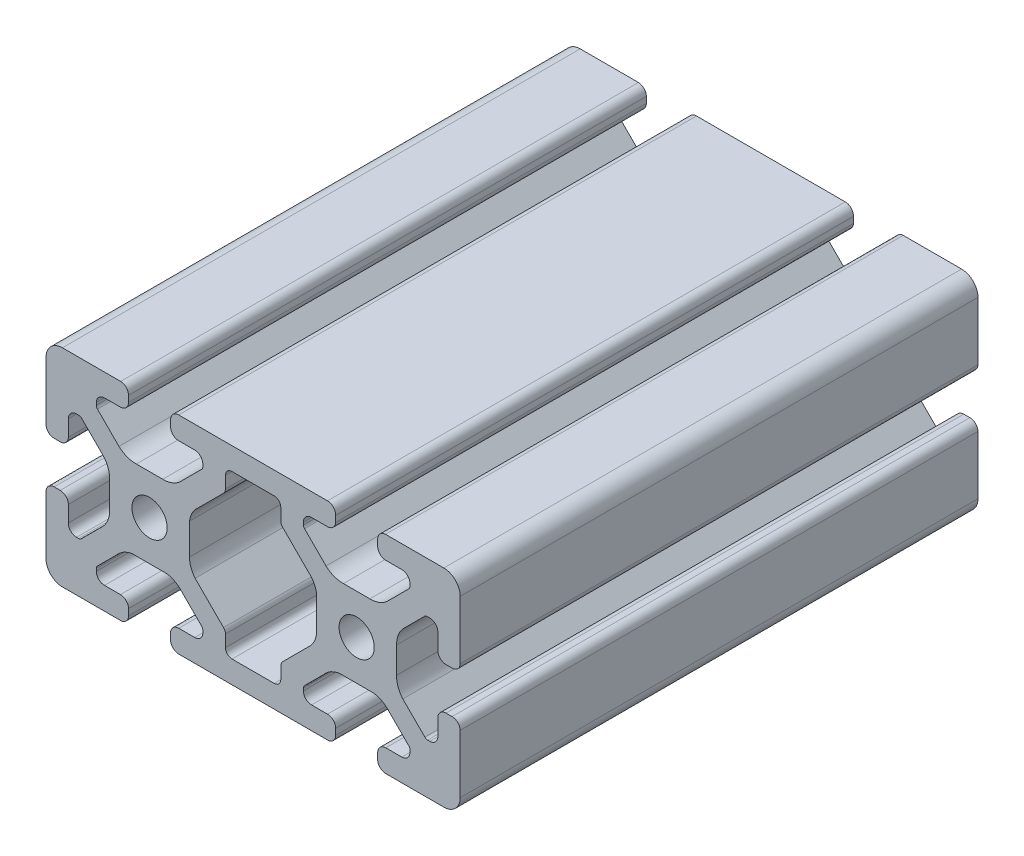
from build123d import *

# Parameters (mm, degrees)
SKETCH1_R           = 3.4
BOSS_EXTRUDE1_DEPTH = 100


with BuildPart() as part:
    # Sketch1 → Boss-Extrude1 (new body)
    with BuildSketch(Plane.XY):
        with BuildLine():
            Line((-14.371895096, 20), (14.371895096, 20))
            ThreePointArc((14.371895096, 20), (15.50899084, 19.51254943), (15.94, 18.352883145))
            Line((15.94, 18.352883145), (15.94, 17.172883145))
            ThreePointArc((15.94, 17.172883145), (15.453758432, 16.112250378), (14.37, 15.68))
            Line((14.37, 15.68), (11.285, 15.68))
            ThreePointArc((11.285, 15.68), (10.174842354, 15.220157646), (9.715, 14.11))
            Line((9.715, 14.11), (9.715, 13.654503602))
            ThreePointArc((9.715, 13.654503602), (9.772851555, 13.363664194), (9.937598846, 13.117102448))
            Line((9.937598846, 13.117102448), (14.091872782, 8.962828513))
            ThreePointArc((14.091872782, 8.962828513), (15.647416634, 8.002049766), (17.450629992, 7.7))
            Line((17.450629992, 7.7), (22.549370008, 7.7))
            ThreePointArc((22.549370008, 7.7), (24.352583366, 8.002049766), (25.908127218, 8.962828513))
            Line((25.908127218, 8.962828513), (30.062401154, 13.117102448))
            ThreePointArc((30.062401154, 13.117102448), (30.227148445, 13.363664194), (30.285, 13.654503602))
            Line((30.285, 13.654503602), (30.285, 14.11))
            ThreePointArc((30.285, 14.11), (29.825157646, 15.220157646), (28.715, 15.68))
            Line((28.715, 15.68), (25.63, 15.68))
            ThreePointArc((25.63, 15.68), (24.519842354, 16.139842354), (24.06, 17.25))
            Line((24.06, 17.25), (24.06, 18.431164164))
            ThreePointArc((24.06, 18.431164164), (24.498672143, 19.519739968), (25.569550674, 20))
            Line((25.569550674, 20), (33, 20))
            Line((33, 20), (36.83, 20))
            ThreePointArc((36.83, 20), (39.067780363, 19.075288119), (40, 16.840624931))
            Line((40, 16.840624931), (40, 13.010624931))
            Line((40, 13.010624931), (40, 5.582508737))
            ThreePointArc((40, 5.582508737), (39.486387554, 4.464397964), (38.324306777, 4.06))
            Line((38.324306777, 4.06), (37.144306789, 4.06))
            ThreePointArc((37.144306789, 4.06), (36.103082753, 4.554299861), (35.68, 5.626438298))
            Line((35.68, 5.626438298), (35.68, 8.711438298))
            ThreePointArc((35.68, 8.711438298), (35.220157646, 9.821595945), (34.11, 10.281438298))
            Line((34.11, 10.281438298), (33.650941901, 10.281438298))
            ThreePointArc((33.650941901, 10.281438298), (33.360102492, 10.223586743), (33.113540747, 10.058839452))
            Line((33.113540747, 10.058839452), (29.01112516, 5.956423865))
            ThreePointArc((29.01112516, 5.956423865), (28.027864944, 4.392105869), (27.715866667, 2.570966522))
            Line((27.715866667, 2.570966522), (27.715866667, -2.502014759))
            ThreePointArc((27.715866667, -2.502014759), (27.988460835, -4.298258683), (28.915473265, -5.86077197))
            Line((28.915473265, -5.86077197), (33.171894658, -10.117193363))
            ThreePointArc((33.171894658, -10.117193363), (33.418456403, -10.281940654), (33.709295811, -10.339792209))
            Line((33.709295811, -10.339792209), (34.110956402, -10.339792209))
            ThreePointArc((34.110956402, -10.339792209), (35.240319888, -9.860405851), (35.68, -8.714999999))
            Line((35.68, -8.714999999), (35.68, -5.629999999))
            ThreePointArc((35.68, -5.629999999), (36.139842353, -4.519842353), (37.249999999, -4.06))
            Line((37.249999999, -4.06), (38.431164149, -4.06))
            ThreePointArc((38.431164149, -4.06), (39.519739962, -4.498672137), (40, -5.569550674))
            Line((40, -5.569550674), (40, -13))
            Line((40, -13), (40, -16.83))
            ThreePointArc((40, -16.83), (39.153330856, -18.99480488), (37.057427332, -20))
            Line((37.057427332, -20), (33.227427332, -20))
            Line((33.227427332, -20), (25.796978006, -20))
            ThreePointArc((25.796978006, -20), (24.580537154, -19.606606664), (24.06, -18.438904761))
            Line((24.06, -18.438904761), (24.06, -17.25))
            ThreePointArc((24.06, -17.25), (24.519842354, -16.139842354), (25.63, -15.68))
            Line((25.63, -15.68), (28.715, -15.68))
            ThreePointArc((28.715, -15.68), (29.825157646, -15.220157646), (30.285, -14.11))
            Line((30.285, -14.11), (30.285, -13.654503602))
            ThreePointArc((30.285, -13.654503602), (30.227148445, -13.363664194), (30.062401154, -13.117102448))
            Line((30.062401154, -13.117102448), (26.309520343, -9.364221638))
            ThreePointArc((26.309520343, -9.364221638), (24.979669869, -8.257223741), (23.341546451, -7.7))
            Line((23.341546451, -7.7), (16.658453549, -7.7))
            ThreePointArc((16.658453549, -7.7), (15.020330131, -8.257223741), (13.690479657, -9.364221638))
            Line((13.690479657, -9.364221638), (9.937598846, -13.117102448))
            ThreePointArc((9.937598846, -13.117102448), (9.772851555, -13.363664194), (9.715, -13.654503602))
            Line((9.715, -13.654503602), (9.715, -14.11))
            ThreePointArc((9.715, -14.11), (10.174842354, -15.220157646), (11.285, -15.68))
            Line((11.285, -15.68), (14.37, -15.68))
            ThreePointArc((14.37, -15.68), (15.480157646, -16.139842354), (15.94, -17.25))
            Line((15.94, -17.25), (15.94, -18.43))
            ThreePointArc((15.94, -18.43), (15.480157646, -19.540157646), (14.37, -20))
            Line((14.37, -20), (5.99100603, -20))
            Line((5.99100603, -20), (-1.780052417, -20))
            Line((-1.780052417, -20), (-5.99100603, -20))
            Line((-5.99100603, -20), (-14.37, -20))
            ThreePointArc((-14.37, -20), (-15.480157646, -19.540157646), (-15.94, -18.43))
            Line((-15.94, -18.43), (-15.94, -17.25))
            ThreePointArc((-15.94, -17.25), (-15.480157646, -16.139842354), (-14.37, -15.68))
            Line((-14.37, -15.68), (-11.285, -15.68))
            ThreePointArc((-11.285, -15.68), (-10.174842354, -15.220157646), (-9.715, -14.11))
            Line((-9.715, -14.11), (-9.715, -13.654503602))
            ThreePointArc((-9.715, -13.654503602), (-9.772851555, -13.363664194), (-9.937598846, -13.117102448))
            Line((-9.937598846, -13.117102448), (-13.690479657, -9.364221638))
            ThreePointArc((-13.690479657, -9.364221638), (-15.020330131, -8.257223741), (-16.658453549, -7.7))
            Line((-16.658453549, -7.7), (-23.341546451, -7.7))
            ThreePointArc((-23.341546451, -7.7), (-24.979669869, -8.257223741), (-26.309520343, -9.364221638))
            Line((-26.309520343, -9.364221638), (-30.062401154, -13.117102448))
            ThreePointArc((-30.062401154, -13.117102448), (-30.227148445, -13.363664194), (-30.285, -13.654503602))
            Line((-30.285, -13.654503602), (-30.285, -14.11))
            ThreePointArc((-30.285, -14.11), (-29.825157646, -15.220157646), (-28.715, -15.68))
            Line((-28.715, -15.68), (-25.63, -15.68))
            ThreePointArc((-25.63, -15.68), (-24.519842354, -16.139842354), (-24.06, -17.25))
            Line((-24.06, -17.25), (-24.06, -18.438904761))
            ThreePointArc((-24.06, -18.438904761), (-24.580537154, -19.606606664), (-25.796978006, -20))
            Line((-25.796978006, -20), (-33.227427332, -20))
            Line((-33.227427332, -20), (-37.057427332, -20))
            ThreePointArc((-37.057427332, -20), (-39.153330856, -18.99480488), (-40, -16.83))
            Line((-40, -16.83), (-40, -13))
            Line((-40, -13), (-40, -5.569550674))
            ThreePointArc((-40, -5.569550674), (-39.519320595, -4.498268351), (-38.43, -4.06))
            Line((-38.43, -4.06), (-37.249999999, -4.06))
            ThreePointArc((-37.249999999, -4.06), (-36.139842353, -4.519842353), (-35.68, -5.629999999))
            Line((-35.68, -5.629999999), (-35.68, -8.714999999))
            ThreePointArc((-35.68, -8.714999999), (-35.240319888, -9.860405851), (-34.110956402, -10.339792209))
            Line((-34.110956402, -10.339792209), (-33.709295811, -10.339792209))
            ThreePointArc((-33.709295811, -10.339792209), (-33.418456403, -10.281940654), (-33.171894658, -10.117193363))
            Line((-33.171894658, -10.117193363), (-28.915473265, -5.86077197))
            ThreePointArc((-28.915473265, -5.86077197), (-27.988460835, -4.298258683), (-27.715866667, -2.502014759))
            Line((-27.715866667, -2.502014759), (-27.715866667, 2.570966522))
            ThreePointArc((-27.715866667, 2.570966522), (-28.027864944, 4.392105869), (-29.01112516, 5.956423865))
            Line((-29.01112516, 5.956423865), (-33.113540747, 10.058839452))
            ThreePointArc((-33.113540747, 10.058839452), (-33.360102492, 10.223586743), (-33.650941901, 10.281438298))
            Line((-33.650941901, 10.281438298), (-34.11, 10.281438298))
            ThreePointArc((-34.11, 10.281438298), (-35.220157646, 9.821595945), (-35.68, 8.711438298))
            Line((-35.68, 8.711438298), (-35.68, 5.626438298))
            ThreePointArc((-35.68, 5.626438298), (-36.103082753, 4.554299861), (-37.144306789, 4.06))
            Line((-37.144306789, 4.06), (-38.324306777, 4.06))
            ThreePointArc((-38.324306777, 4.06), (-39.486387554, 4.464397964), (-40, 5.582508737))
            Line((-40, 5.582508737), (-40, 13.010624931))
            Line((-40, 13.010624931), (-40, 16.840624931))
            ThreePointArc((-40, 16.840624931), (-39.067780363, 19.075288119), (-36.83, 20))
            Line((-36.83, 20), (-33, 20))
            Line((-33, 20), (-25.569550674, 20))
            ThreePointArc((-25.569550674, 20), (-24.498672143, 19.519739968), (-24.06, 18.431164164))
            Line((-24.06, 18.431164164), (-24.06, 17.25))
            ThreePointArc((-24.06, 17.25), (-24.519842354, 16.139842354), (-25.63, 15.68))
            Line((-25.63, 15.68), (-28.715, 15.68))
            ThreePointArc((-28.715, 15.68), (-29.825157646, 15.220157646), (-30.285, 14.11))
            Line((-30.285, 14.11), (-30.285, 13.654503602))
            ThreePointArc((-30.285, 13.654503602), (-30.227148445, 13.363664194), (-30.062401154, 13.117102448))
            Line((-30.062401154, 13.117102448), (-25.908127218, 8.962828513))
            ThreePointArc((-25.908127218, 8.962828513), (-24.352583366, 8.002049766), (-22.549370008, 7.7))
            Line((-22.549370008, 7.7), (-17.450629992, 7.7))
            ThreePointArc((-17.450629992, 7.7), (-15.647416634, 8.002049766), (-14.091872782, 8.962828513))
            Line((-14.091872782, 8.962828513), (-9.937598846, 13.117102448))
            ThreePointArc((-9.937598846, 13.117102448), (-9.772851555, 13.363664194), (-9.715, 13.654503602))
            Line((-9.715, 13.654503602), (-9.715, 14.11))
            ThreePointArc((-9.715, 14.11), (-10.174842354, 15.220157646), (-11.285, 15.68))
            Line((-11.285, 15.68), (-14.37, 15.68))
            ThreePointArc((-14.37, 15.68), (-15.453758432, 16.112250378), (-15.94, 17.172883145))
            Line((-15.94, 17.172883145), (-15.94, 18.352883145))
            ThreePointArc((-15.94, 18.352883145), (-15.50899084, 19.51254943), (-14.371895096, 20))
        make_face()
        with Locations((-20, 0)):
            Circle(SKETCH1_R, mode=Mode.SUBTRACT)
        with Locations((20, 0)):
            Circle(SKETCH1_R, mode=Mode.SUBTRACT)
        with BuildLine():
            Line((4.071751167, 15.68), (-4.071751167, 15.68))
            ThreePointArc((-4.071751167, 15.68), (-4.969776779, 15.308025612), (-5.341751167, 14.41))
            Line((-5.341751167, 14.41), (-5.341751167, 12.129598762))
            ThreePointArc((-5.341751167, 12.129598762), (-5.438424161, 11.643590803), (-5.713725555, 11.23157315))
            Line((-5.713725555, 11.23157315), (-10.598777023, 6.346521682))
            ThreePointArc((-10.598777023, 6.346521682), (-11.737774423, 4.964558417), (-12.284133333, 3.259087959))
            Line((-12.284133333, 3.259087959), (-12.284133333, -2.724972544))
            ThreePointArc((-12.284133333, -2.724972544), (-12.005210609, -4.328708179), (-11.201199443, -5.744099262))
            Line((-11.201199443, -5.744099262), (-5.713725555, -11.23157315))
            ThreePointArc((-5.713725555, -11.23157315), (-5.438424161, -11.643590803), (-5.341751167, -12.129598762))
            Line((-5.341751167, -12.129598762), (-5.341751167, -14.41))
            ThreePointArc((-5.341751167, -14.41), (-4.969776779, -15.308025612), (-4.071751167, -15.68))
            Line((-4.071751167, -15.68), (4.071751167, -15.68))
            ThreePointArc((4.071751167, -15.68), (4.969776779, -15.308025612), (5.341751167, -14.41))
            Line((5.341751167, -14.41), (5.341751167, -12.129598762))
            ThreePointArc((5.341751167, -12.129598762), (5.438424161, -11.643590803), (5.713725555, -11.23157315))
            Line((5.713725555, -11.23157315), (11.201199443, -5.744099262))
            ThreePointArc((11.201199443, -5.744099262), (12.005210609, -4.328708179), (12.284133333, -2.724972544))
            Line((12.284133333, -2.724972544), (12.284133333, 3.259087959))
            ThreePointArc((12.284133333, 3.259087959), (11.737774423, 4.964558417), (10.598777023, 6.346521682))
            Line((10.598777023, 6.346521682), (5.713725555, 11.23157315))
            ThreePointArc((5.713725555, 11.23157315), (5.438424161, 11.643590803), (5.341751167, 12.129598762))
            Line((5.341751167, 12.129598762), (5.341751167, 14.41))
            ThreePointArc((5.341751167, 14.41), (4.969776779, 15.308025612), (4.071751167, 15.68))
        make_face(mode=Mode.SUBTRACT)
    extrude(amount=BOSS_EXTRUDE1_DEPTH)


solid = part.part
